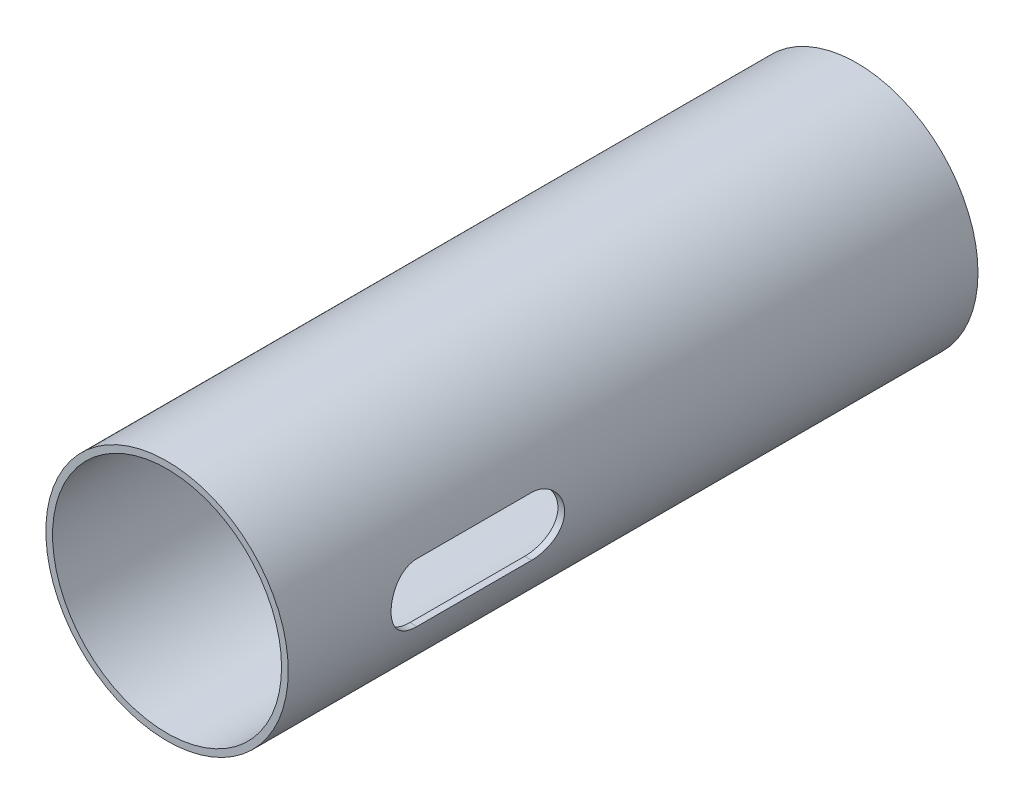
from build123d import *

# Parameters (mm, degrees)
SKETCH1_R           = 12.630912
BOSS_EXTRUDE1_DEPTH = 71.882
SHELL1_T            = -0.6985
CUT_EXTRUDE1_DEPTH  = 71.882


with BuildPart() as part:
    # Sketch1 → Boss-Extrude1 (new body)
    with BuildSketch(Plane.XY):
        with Locations((-89.675021381, 9.53355709)):
            Circle(SKETCH1_R)
    extrude(amount=BOSS_EXTRUDE1_DEPTH)

    # Shell1
    shell1_openings = [part.faces().sort_by_distance(p)[0] for p in [
        (-89.675021381, 9.53355709, 71.882),
        (-89.675021381, 9.53355709, 0),
    ]]
    offset(amount=SHELL1_T, openings=shell1_openings, kind=Kind.INTERSECTION)

    # Sketch4 → Cut-Extrude1 (cut)
    with BuildSketch(Plane(origin=(-89.662, 0, 0), x_dir=(0, 0, -1), z_dir=(1, 0, 0))):
        with BuildLine():
            Line((-58.1025, 12.59425709), (-46.1391, 12.59425709))
            ThreePointArc((-46.1391, 12.59425709), (-43.0784, 9.53355709), (-46.1391, 6.47285709))
            Line((-46.1391, 6.47285709), (-58.1025, 6.47285709))
            ThreePointArc((-58.1025, 6.47285709), (-61.1632, 9.53355709), (-58.1025, 12.59425709))
        make_face()
    extrude(amount=CUT_EXTRUDE1_DEPTH, mode=Mode.SUBTRACT)


solid = part.part
